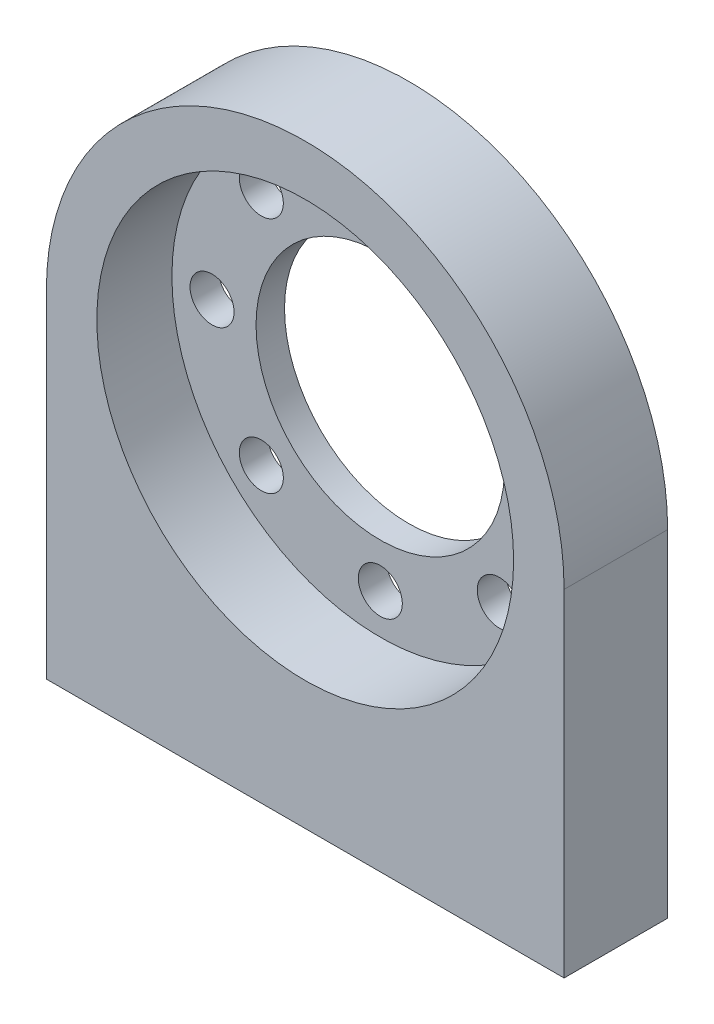
from build123d import *

# Parameters (mm, degrees)
ESQUISSE1_R             = 9.6
BOSS_EXTRU_1_DEPTH      = 8
ESQUISSE2_R             = 16.1
ENL_V_MAT_EXTRU_1_DEPTH = 5.8
ENL_V_MAT_EXTRU_2_REACH = 10
ESQUISSE3_R             = 1.7
ESQUISSE4_R             = 1.25
ENL_V_MAT_EXTRU_3_DEPTH = 15


with BuildPart() as part:
    # Esquisse1 → Boss.-Extru.1 (new body)
    with BuildSketch(Plane.XY):
        with BuildLine():
            Line((-20, 0), (-20, -26))
            Line((-20, -26), (20, -26))
            Line((20, -26), (20, 0))
            ThreePointArc((20, 0), (0, 20), (-20, 0))
        make_face()
        Circle(ESQUISSE1_R, mode=Mode.SUBTRACT)
    extrude(amount=BOSS_EXTRU_1_DEPTH)

    # Esquisse2 → Enlèv. mat.-Extru.1 (cut)
    with BuildSketch(Plane.XY.offset(8)):
        Circle(ESQUISSE2_R)
    extrude(amount=-ENL_V_MAT_EXTRU_1_DEPTH, mode=Mode.SUBTRACT)

    # Esquisse3 → Enlèv. mat.-Extru.2 (cut, up to next)
    with BuildSketch(Plane(origin=(0, 0, 0), x_dir=(-1, 0, 0), z_dir=(0, 0, -1)), mode=Mode.PRIVATE) as enl_v_mat_extru_2_sk1:
        with Locations((0, 13)):
            Circle(ESQUISSE3_R)
    enl_v_mat_extru_2_tool1 = extrude(enl_v_mat_extru_2_sk1.sketch, amount=-ENL_V_MAT_EXTRU_2_REACH, mode=Mode.PRIVATE) & part.part
    add(enl_v_mat_extru_2_tool1.solids().sort_by_distance((0, 13, 0))[0], mode=Mode.SUBTRACT)
    # Esquisse3 → Enlèv. mat.-Extru.2 (cut, up to next)
    with BuildSketch(Plane(origin=(0, 0, 0), x_dir=(-1, 0, 0), z_dir=(0, 0, -1)), mode=Mode.PRIVATE) as enl_v_mat_extru_2_sk2:
        with Locations((9.192388155, 9.192388155)):
            Circle(ESQUISSE3_R)
    enl_v_mat_extru_2_tool2 = extrude(enl_v_mat_extru_2_sk2.sketch, amount=-ENL_V_MAT_EXTRU_2_REACH, mode=Mode.PRIVATE) & part.part
    add(enl_v_mat_extru_2_tool2.solids().sort_by_distance((-9.192388, 9.192388, 0))[0], mode=Mode.SUBTRACT)
    # Esquisse3 → Enlèv. mat.-Extru.2 (cut, up to next)
    with BuildSketch(Plane(origin=(0, 0, 0), x_dir=(-1, 0, 0), z_dir=(0, 0, -1)), mode=Mode.PRIVATE) as enl_v_mat_extru_2_sk3:
        with Locations((13, 0)):
            Circle(ESQUISSE3_R)
    enl_v_mat_extru_2_tool3 = extrude(enl_v_mat_extru_2_sk3.sketch, amount=-ENL_V_MAT_EXTRU_2_REACH, mode=Mode.PRIVATE) & part.part
    add(enl_v_mat_extru_2_tool3.solids().sort_by_distance((-13, 0, 0))[0], mode=Mode.SUBTRACT)
    # Esquisse3 → Enlèv. mat.-Extru.2 (cut, up to next)
    with BuildSketch(Plane(origin=(0, 0, 0), x_dir=(-1, 0, 0), z_dir=(0, 0, -1)), mode=Mode.PRIVATE) as enl_v_mat_extru_2_sk4:
        with Locations((9.192388155, -9.192388155)):
            Circle(ESQUISSE3_R)
    enl_v_mat_extru_2_tool4 = extrude(enl_v_mat_extru_2_sk4.sketch, amount=-ENL_V_MAT_EXTRU_2_REACH, mode=Mode.PRIVATE) & part.part
    add(enl_v_mat_extru_2_tool4.solids().sort_by_distance((-9.192388, -9.192388, 0))[0], mode=Mode.SUBTRACT)
    # Esquisse3 → Enlèv. mat.-Extru.2 (cut, up to next)
    with BuildSketch(Plane(origin=(0, 0, 0), x_dir=(-1, 0, 0), z_dir=(0, 0, -1)), mode=Mode.PRIVATE) as enl_v_mat_extru_2_sk5:
        with Locations((0, -13)):
            Circle(ESQUISSE3_R)
    enl_v_mat_extru_2_tool5 = extrude(enl_v_mat_extru_2_sk5.sketch, amount=-ENL_V_MAT_EXTRU_2_REACH, mode=Mode.PRIVATE) & part.part
    add(enl_v_mat_extru_2_tool5.solids().sort_by_distance((0, -13, 0))[0], mode=Mode.SUBTRACT)
    # Esquisse3 → Enlèv. mat.-Extru.2 (cut, up to next)
    with BuildSketch(Plane(origin=(0, 0, 0), x_dir=(-1, 0, 0), z_dir=(0, 0, -1)), mode=Mode.PRIVATE) as enl_v_mat_extru_2_sk6:
        with Locations((-9.192388155, -9.192388155)):
            Circle(ESQUISSE3_R)
    enl_v_mat_extru_2_tool6 = extrude(enl_v_mat_extru_2_sk6.sketch, amount=-ENL_V_MAT_EXTRU_2_REACH, mode=Mode.PRIVATE) & part.part
    add(enl_v_mat_extru_2_tool6.solids().sort_by_distance((9.192388, -9.192388, 0))[0], mode=Mode.SUBTRACT)
    # Esquisse3 → Enlèv. mat.-Extru.2 (cut, up to next)
    with BuildSketch(Plane(origin=(0, 0, 0), x_dir=(-1, 0, 0), z_dir=(0, 0, -1)), mode=Mode.PRIVATE) as enl_v_mat_extru_2_sk7:
        with Locations((-13, 0)):
            Circle(ESQUISSE3_R)
    enl_v_mat_extru_2_tool7 = extrude(enl_v_mat_extru_2_sk7.sketch, amount=-ENL_V_MAT_EXTRU_2_REACH, mode=Mode.PRIVATE) & part.part
    add(enl_v_mat_extru_2_tool7.solids().sort_by_distance((13, 0, 0))[0], mode=Mode.SUBTRACT)
    # Esquisse3 → Enlèv. mat.-Extru.2 (cut, up to next)
    with BuildSketch(Plane(origin=(0, 0, 0), x_dir=(-1, 0, 0), z_dir=(0, 0, -1)), mode=Mode.PRIVATE) as enl_v_mat_extru_2_sk8:
        with Locations((-9.192388155, 9.192388155)):
            Circle(ESQUISSE3_R)
    enl_v_mat_extru_2_tool8 = extrude(enl_v_mat_extru_2_sk8.sketch, amount=-ENL_V_MAT_EXTRU_2_REACH, mode=Mode.PRIVATE) & part.part
    add(enl_v_mat_extru_2_tool8.solids().sort_by_distance((9.192388, 9.192388, 0))[0], mode=Mode.SUBTRACT)

    # Esquisse4 → Enlèv. mat.-Extru.3 (cut)
    with BuildSketch(Plane.XZ.offset(26)):
        with Locations((-16, 4)):
            Circle(ESQUISSE4_R)
        with Locations((16, 4)):
            Circle(ESQUISSE4_R)
    extrude(amount=-ENL_V_MAT_EXTRU_3_DEPTH, mode=Mode.SUBTRACT)


solid = part.part
